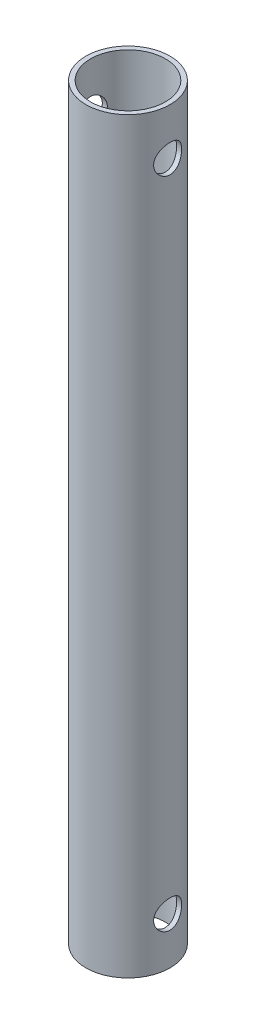
from build123d import *

# Parameters (mm, degrees)
CROQUIS1_R                 = 4.5
CROQUIS1_R_2               = 4
SALIENTE_EXTRUIR1_DEPTH    = 80
CROQUIS2_R                 = 1.5
CORTAR_EXTRUIR1_DEPTH      = 5.5
CORTAR_EXTRUIR1_DEPTH_BACK = 5.5


with BuildPart() as part:
    # Croquis1 → Saliente-Extruir1 (new body)
    with BuildSketch(Plane(origin=(0, 0, 0), x_dir=(1, 0, 0), z_dir=(0, 1, 0))):
        Circle(CROQUIS1_R)
        Circle(CROQUIS1_R_2, mode=Mode.SUBTRACT)
    extrude(amount=SALIENTE_EXTRUIR1_DEPTH)

    # Croquis2 → Cortar-Extruir1 (cut, two sides)
    with BuildSketch(Plane(origin=(0, 0, 0), x_dir=(0, 0, -1), z_dir=(1, 0, 0))) as cortar_extruir1_sk:
        with Locations((0, 75)):
            Circle(CROQUIS2_R)
        with Locations((0, 5)):
            Circle(CROQUIS2_R)
    extrude(amount=CORTAR_EXTRUIR1_DEPTH, mode=Mode.SUBTRACT)
    extrude(cortar_extruir1_sk.sketch, amount=-CORTAR_EXTRUIR1_DEPTH_BACK, mode=Mode.SUBTRACT)


solid = part.part
